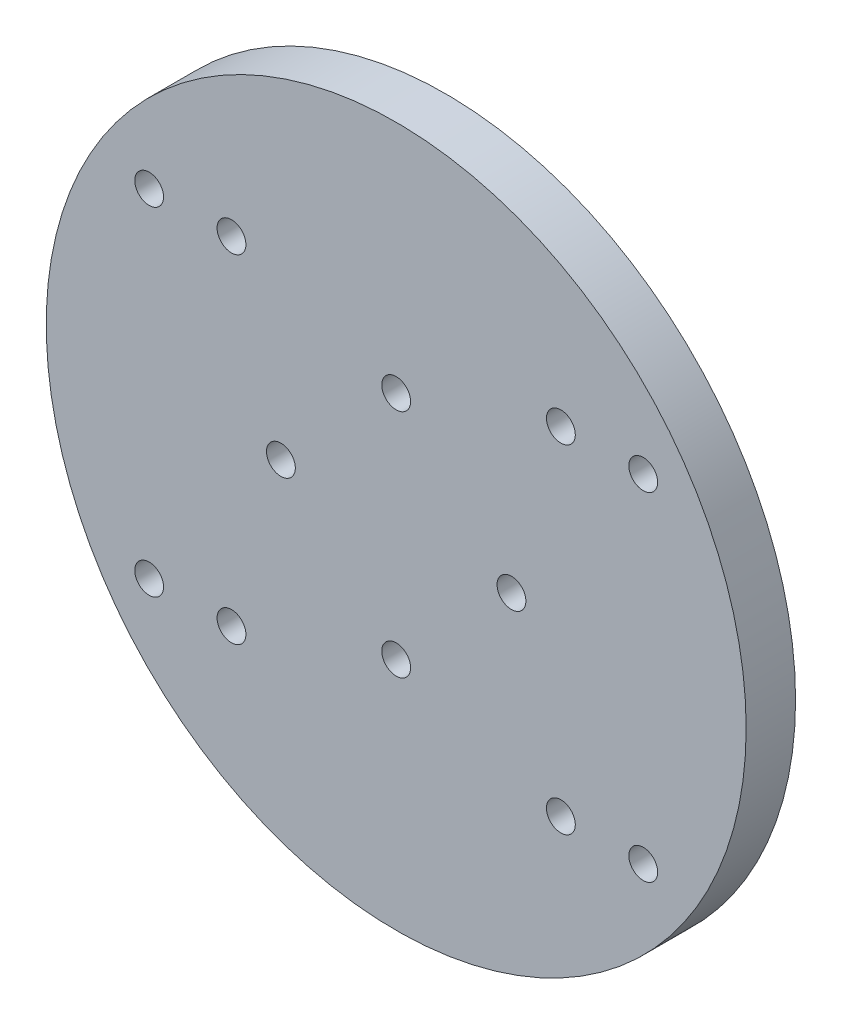
from build123d import *

# Parameters (mm, degrees)
SKETCH1_R               = 42.5
BOSS_EXTRUDE1_DEPTH     = 6
SKETCH2_R               = 22
BOSS_EXTRUDE2_DEPTH     = 6
SKETCH3_R               = 20.1
BOSS_EXTRUDE3_DEPTH     = 4.7
SKETCH4_R               = 18.1
CUT_EXTRUDE1_DEPTH      = 11
SKETCH5_R               = 1.75
CUT_EXTRUDE2_DEPTH      = 6.7
SKETCH6_R               = 1.75
CUT_EXTRUDE3_DEPTH      = 12
CUT_EXTRUDE3_DEPTH_BACK = 6.7
SKETCH7_R               = 2.9
CUT_EXTRUDE5_DEPTH      = 3.3
SKETCH8_R               = 1.75
CUT_EXTRUDE6_DEPTH      = 10
SKETCH9_R               = 2.9
CUT_EXTRUDE7_DEPTH      = 3.3


with BuildPart() as part:
    # Sketch1 → Boss-Extrude1 (new body)
    with BuildSketch(Plane.XY):
        Circle(SKETCH1_R)
    extrude(amount=BOSS_EXTRUDE1_DEPTH)

    # Sketch2 → Boss-Extrude2 (add)
    with BuildSketch(Plane(origin=(0, 0, 0), x_dir=(-1, 0, 0), z_dir=(0, 0, -1))):
        Circle(SKETCH2_R)
    extrude(amount=BOSS_EXTRUDE2_DEPTH)

    # Sketch3 → Boss-Extrude3 (add)
    with BuildSketch(Plane(origin=(0, 0, -6), x_dir=(-1, 0, 0), z_dir=(0, 0, -1))):
        Circle(SKETCH3_R)
    extrude(amount=BOSS_EXTRUDE3_DEPTH)

    # Sketch4 → Cut-Extrude1 (cut)
    with BuildSketch(Plane(origin=(0, 0, -10.7), x_dir=(-1, 0, 0), z_dir=(0, 0, -1))):
        Circle(SKETCH4_R)
    extrude(amount=-CUT_EXTRUDE1_DEPTH, mode=Mode.SUBTRACT)

    # Sketch5 → Cut-Extrude2 (cut, through all)
    with BuildSketch(Plane(origin=(0, 0, 0.3), x_dir=(-1, 0, 0), z_dir=(0, 0, -1))):
        with Locations((14, 0)):
            Circle(SKETCH5_R)
        with Locations((0, -14)):
            Circle(SKETCH5_R)
        with Locations((-14, 0)):
            Circle(SKETCH5_R)
        with Locations((0, 14)):
            Circle(SKETCH5_R)
    extrude(amount=-CUT_EXTRUDE2_DEPTH, mode=Mode.SUBTRACT)

    # Sketch6 → Cut-Extrude3 (cut, two sides)
    with BuildSketch(Plane(origin=(0, 0, 0.3), x_dir=(-1, 0, 0), z_dir=(0, 0, -1))) as cut_extrude3_sk:
        with Locations((19.999991423, -20.5)):
            Circle(SKETCH6_R)
        with Locations((-19.999991423, 20.5)):
            Circle(SKETCH6_R)
        with Locations((-19.999991423, -20.5)):
            Circle(SKETCH6_R)
        with Locations((19.999991423, 20.5)):
            Circle(SKETCH6_R)
    extrude(amount=CUT_EXTRUDE3_DEPTH, mode=Mode.SUBTRACT)
    extrude(cut_extrude3_sk.sketch, amount=-CUT_EXTRUDE3_DEPTH_BACK, mode=Mode.SUBTRACT)

    # Sketch7 → Cut-Extrude5 (cut)
    with BuildSketch(Plane.XY):
        with Locations((19.999991423, 20.5)):
            Circle(SKETCH7_R)
        with Locations((-19.999991423, 20.5)):
            Circle(SKETCH7_R)
        with Locations((-19.999991423, -20.5)):
            Circle(SKETCH7_R)
        with Locations((19.999991423, -20.5)):
            Circle(SKETCH7_R)
    extrude(amount=CUT_EXTRUDE5_DEPTH, mode=Mode.SUBTRACT)

    # Sketch8 → Cut-Extrude6 (cut)
    with BuildSketch(Plane.XY.offset(6)):
        with Locations((-29.999991423, -20.5)):
            Circle(SKETCH8_R)
        with Locations((-29.999991423, 20.5)):
            Circle(SKETCH8_R)
        with Locations((29.999991423, 20.5)):
            Circle(SKETCH8_R)
        with Locations((29.999991423, -20.5)):
            Circle(SKETCH8_R)
    extrude(amount=-CUT_EXTRUDE6_DEPTH, mode=Mode.SUBTRACT)

    # Sketch9 → Cut-Extrude7 (cut)
    with BuildSketch(Plane(origin=(0, 0, 0), x_dir=(-1, 0, 0), z_dir=(0, 0, -1))):
        with Locations((-29.999991423, -20.5)):
            Circle(SKETCH9_R)
        with Locations((-29.999991423, 20.5)):
            Circle(SKETCH9_R)
        with Locations((29.999991423, -20.5)):
            Circle(SKETCH9_R)
        with Locations((29.999991423, 20.5)):
            Circle(SKETCH9_R)
    extrude(amount=-CUT_EXTRUDE7_DEPTH, mode=Mode.SUBTRACT)


solid = part.part
